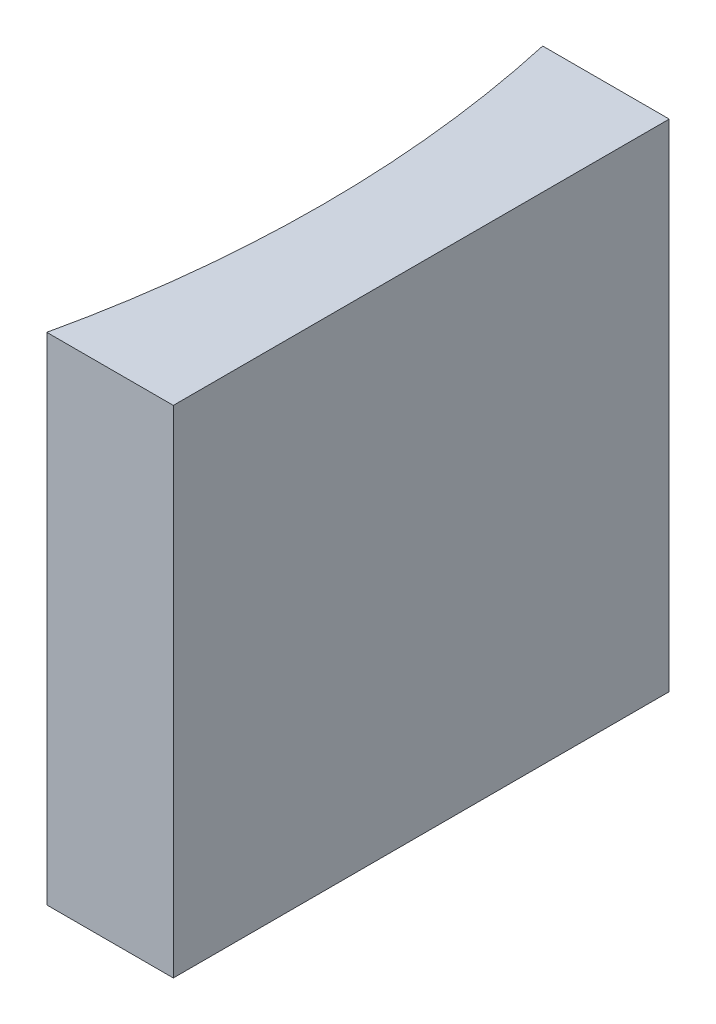
from build123d import *

# Parameters (mm, degrees)
EXTRUDE_1_DEPTH = 10


with BuildPart() as part:
    # 草图1 → 凸台-拉伸1 (new body)
    with BuildSketch(Plane(origin=(0, 0, 0), x_dir=(1, 0, 0), z_dir=(0, 1, 0))):
        with BuildLine():
            Line((0, 0), (0, -10))
            Line((0, -10), (-2.55202289, -10))
            ThreePointArc((-2.55202289, -10), (-2, -5), (-2.55202289, 0))
            Line((-2.55202289, 0), (0, 0))
        make_face()
    extrude(amount=EXTRUDE_1_DEPTH)


solid = part.part
